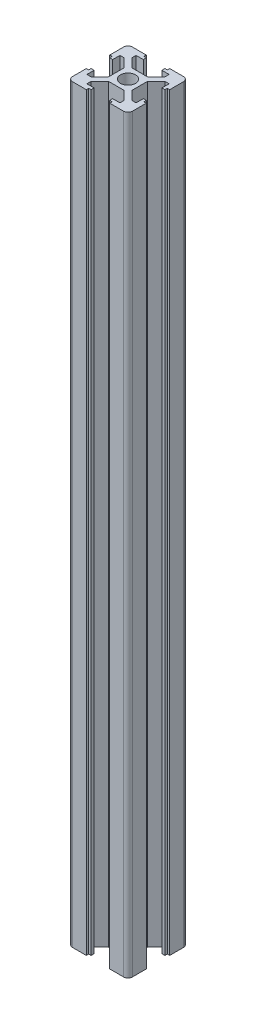
from build123d import *

# Parameters (mm, degrees)
SKETCH1_R           = 2.5
BOSS_EXTRUDE1_DEPTH = 250


with BuildPart() as part:
    # Sketch1 → Boss-Extrude1 (new body)
    with BuildSketch(Plane(origin=(0, 0, 0), x_dir=(1, 0, 0), z_dir=(0, 1, 0))):
        with BuildLine():
            Line((3.9, 10), (8.5, 10))
            ThreePointArc((8.5, 10), (9.560660172, 9.560660172), (10, 8.5))
            Line((10, 8.5), (10, 3.9))
            Line((10, 3.9), (9.2, 3.9))
            Line((9.2, 3.9), (9.2, 3.1))
            Line((9.2, 3.1), (8.2, 3.1))
            Line((8.2, 3.1), (8.2, 5.5))
            Line((8.2, 5.5), (6.77, 5.5))
            Line((6.77, 5.5), (3.9, 2.63))
            Line((3.9, 2.63), (3.9, 0))
            Line((3.9, 0), (3.9, -2.63))
            Line((3.9, -2.63), (6.77, -5.5))
            Line((6.77, -5.5), (8.2, -5.5))
            Line((8.2, -5.5), (8.2, -3.1))
            Line((8.2, -3.1), (9.2, -3.1))
            Line((9.2, -3.1), (9.2, -3.9))
            Line((9.2, -3.9), (10, -3.9))
            Line((10, -3.9), (10, -8.5))
            ThreePointArc((10, -8.5), (9.560660172, -9.560660172), (8.5, -10))
            Line((8.5, -10), (3.9, -10))
            Line((3.9, -10), (3.9, -9.2))
            Line((3.9, -9.2), (3.1, -9.2))
            Line((3.1, -9.2), (3.1, -8.2))
            Line((3.1, -8.2), (5.5, -8.2))
            Line((5.5, -8.2), (5.5, -6.77))
            Line((5.5, -6.77), (2.63, -3.9))
            Line((2.63, -3.9), (0, -3.9))
            Line((0, -3.9), (-2.63, -3.9))
            Line((-2.63, -3.9), (-5.5, -6.77))
            Line((-5.5, -6.77), (-5.5, -8.2))
            Line((-5.5, -8.2), (-3.1, -8.2))
            Line((-3.1, -8.2), (-3.1, -9.2))
            Line((-3.1, -9.2), (-3.9, -9.2))
            Line((-3.9, -9.2), (-3.9, -10))
            Line((-3.9, -10), (-8.5, -10))
            ThreePointArc((-8.5, -10), (-9.560660172, -9.560660172), (-10, -8.5))
            Line((-10, -8.5), (-10, -3.9))
            Line((-10, -3.9), (-9.2, -3.9))
            Line((-9.2, -3.9), (-9.2, -3.1))
            Line((-9.2, -3.1), (-8.2, -3.1))
            Line((-8.2, -3.1), (-8.2, -5.5))
            Line((-8.2, -5.5), (-6.77, -5.5))
            Line((-6.77, -5.5), (-3.9, -2.63))
            Line((-3.9, -2.63), (-3.9, 0))
            Line((-3.9, 0), (-3.9, 2.63))
            Line((-3.9, 2.63), (-6.77, 5.5))
            Line((-6.77, 5.5), (-8.2, 5.5))
            Line((-8.2, 5.5), (-8.2, 3.1))
            Line((-8.2, 3.1), (-9.2, 3.1))
            Line((-9.2, 3.1), (-9.2, 3.9))
            Line((-9.2, 3.9), (-10, 3.9))
            Line((-10, 3.9), (-10, 8.5))
            ThreePointArc((-10, 8.5), (-9.560660172, 9.560660172), (-8.5, 10))
            Line((-8.5, 10), (-3.9, 10))
            Line((-3.9, 10), (-3.9, 9.2))
            Line((-3.9, 9.2), (-3.1, 9.2))
            Line((-3.1, 9.2), (-3.1, 8.2))
            Line((-3.1, 8.2), (-5.5, 8.2))
            Line((-5.5, 8.2), (-5.5, 6.77))
            Line((-5.5, 6.77), (-2.63, 3.9))
            Line((-2.63, 3.9), (2.63, 3.9))
            Line((2.63, 3.9), (5.5, 6.77))
            Line((5.5, 6.77), (5.5, 8.2))
            Line((5.5, 8.2), (3.1, 8.2))
            Line((3.1, 8.2), (3.1, 9.2))
            Line((3.1, 9.2), (3.9, 9.2))
            Line((3.9, 9.2), (3.9, 10))
        make_face()
        Circle(SKETCH1_R, mode=Mode.SUBTRACT)
    extrude(amount=BOSS_EXTRUDE1_DEPTH)


solid = part.part
